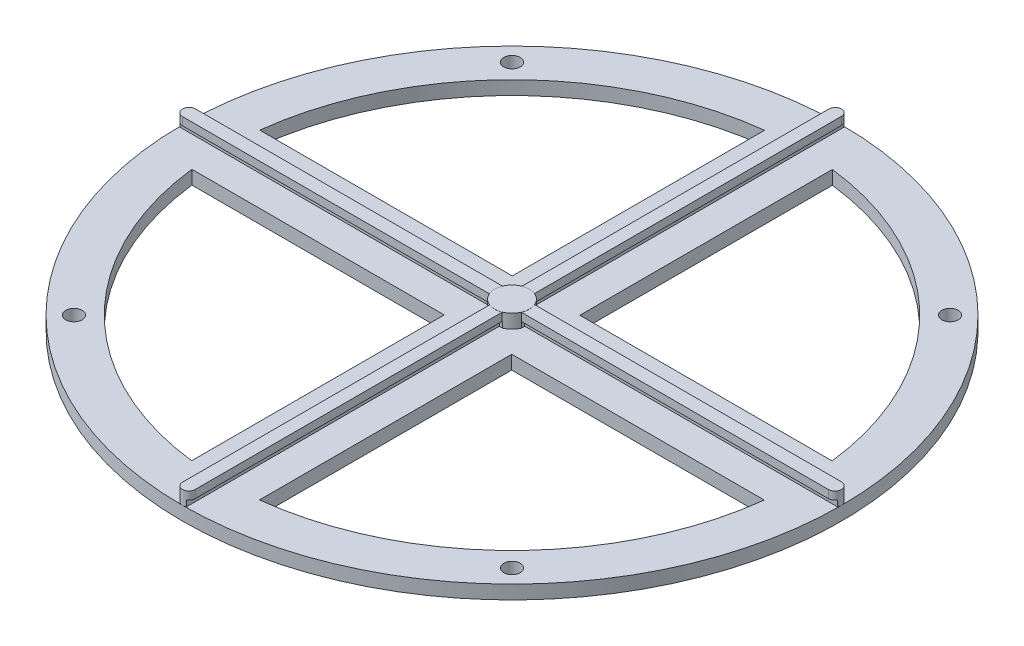
from build123d import *

# Parameters (mm, degrees)
SKETCH1_R                = 76.2
BOSS_EXTRUDE1_DEPTH      = 3.175
BOSS_EXTRUDE2_DEPTH      = 3.175
SKETCH3_R                = 4
BOSS_EXTRUDE3_DEPTH      = 0.0254
BOSS_EXTRUDE3_DEPTH_BACK = 6.35
CUT_EXTRUDE1_DEPTH       = 4.175
SKETCH6_W                = 72.50169985
SKETCH6_H                = 1.3335
CUT_EXTRUDE3_DEPTH       = 0.762
CIRPATTERN1_COUNT        = 4
SKETCH7_W                = 74.062567176
SKETCH7_H                = 1.3335
CUT_EXTRUDE4_DEPTH       = 0.762
CIRPATTERN2_COUNT        = 4
SKETCH8_R                = 1.905
CUT_EXTRUDE5_DEPTH       = 4.175


with BuildPart() as part:
    # Sketch1 → Boss-Extrude1 (new body)
    with BuildSketch(Plane(origin=(0, 0, 0), x_dir=(1, 0, 0), z_dir=(0, 1, 0))):
        Circle(SKETCH1_R)
    extrude(amount=BOSS_EXTRUDE1_DEPTH)

    # Sketch2 → Boss-Extrude2 (add)
    with BuildSketch(Plane(origin=(0, 3.175, 0), x_dir=(1, 0, 0), z_dir=(0, 1, 0))):
        with BuildLine():
            Line((-74.676, 1.524), (74.676, 1.524))
            ThreePointArc((74.676, 1.524), (76.2, 0), (74.676, -1.524))
            Line((74.676, -1.524), (-74.676, -1.524))
            ThreePointArc((-74.676, -1.524), (-76.2, 0), (-74.676, 1.524))
        make_face()
        with BuildLine():
            Line((1.4605, 74.7395), (1.4605, -74.7395))
            ThreePointArc((1.4605, -74.7395), (0, -76.2), (-1.4605, -74.7395))
            Line((-1.4605, -74.7395), (-1.4605, 74.7395))
            ThreePointArc((-1.4605, 74.7395), (0, 76.2), (1.4605, 74.7395))
        make_face()
    extrude(amount=BOSS_EXTRUDE2_DEPTH)

    # Sketch3 → Boss-Extrude3 (add, two sides)
    with BuildSketch(Plane(origin=(0, 6.35, 0), x_dir=(1, 0, 0), z_dir=(0, 1, 0))) as boss_extrude3_sk:
        Circle(SKETCH3_R)
    extrude(amount=BOSS_EXTRUDE3_DEPTH)
    extrude(boss_extrude3_sk.sketch, amount=-BOSS_EXTRUDE3_DEPTH_BACK)

    # Sketch4 → Cut-Extrude1 (cut, through all)
    with BuildSketch(Plane(origin=(0, 3.175, 0), x_dir=(1, 0, 0), z_dir=(0, 1, 0))):
        with BuildLine():
            Line((-7.8105, 7.874), (-39.5605, 7.874))
            Line((-39.5605, 7.874), (-63.009920838, 7.874))
            Line((-63.009920838, 7.874), (-66.208426571, 7.874))
            ThreePointArc((-66.208426571, 7.874), (-47.123731651, 47.168946779), (-7.8105, 66.215947586))
            Line((-7.8105, 66.215947586), (-7.8105, 63.017823588))
            Line((-7.8105, 63.017823588), (-7.8105, 7.874))
        make_face()
        with BuildLine():
            Line((7.874, 63.009920838), (7.874, 66.208426571))
            ThreePointArc((7.874, 66.208426571), (47.168946779, 47.123731651), (66.215947586, 7.8105))
            Line((66.215947586, 7.8105), (63.017823588, 7.8105))
            Line((63.017823588, 7.8105), (7.874, 7.8105))
            Line((7.874, 7.8105), (7.874, 39.5605))
            Line((7.874, 39.5605), (7.874, 63.009920838))
        make_face()
        with BuildLine():
            Line((63.009920838, -7.874), (66.208426571, -7.874))
            ThreePointArc((66.208426571, -7.874), (47.123731651, -47.168946779), (7.8105, -66.215947586))
            Line((7.8105, -66.215947586), (7.8105, -63.017823588))
            Line((7.8105, -63.017823588), (7.8105, -7.874))
            Line((7.8105, -7.874), (39.5605, -7.874))
            Line((39.5605, -7.874), (63.009920838, -7.874))
        make_face()
        with BuildLine():
            Line((-7.874, -63.009920838), (-7.874, -66.208426571))
            ThreePointArc((-7.874, -66.208426571), (-47.168946779, -47.123731651), (-66.215947586, -7.8105))
            Line((-66.215947586, -7.8105), (-63.017823588, -7.8105))
            Line((-63.017823588, -7.8105), (-7.874, -7.8105))
            Line((-7.874, -7.8105), (-7.874, -39.5605))
            Line((-7.874, -39.5605), (-7.874, -63.009920838))
        make_face()
    extrude(amount=-CUT_EXTRUDE1_DEPTH, mode=Mode.SUBTRACT)

    # Sketch6 → Cut-Extrude3 (cut)
    with BuildSketch(Plane.XY.offset(1.524)):
        with Locations((39.949150075, 3.84175)):
            Rectangle(SKETCH6_W, SKETCH6_H)
    cut_extrude3 = extrude(amount=-CUT_EXTRUDE3_DEPTH, mode=Mode.SUBTRACT)

    # CirPattern1: Cut-Extrude3 ×4 about axis
    cirpattern1_axis = Axis((0, 0, 0), (0, 1, 0))
    for i in range(1, CIRPATTERN1_COUNT):
        add(cut_extrude3.rotate(cirpattern1_axis, i * 360 / CIRPATTERN1_COUNT), mode=Mode.SUBTRACT)

    # Sketch7 → Cut-Extrude4 (cut)
    with BuildSketch(Plane(origin=(0, 0, -1.524), x_dir=(-1, 0, 0), z_dir=(0, 0, -1))):
        with Locations((-40.729583738, 3.84175)):
            Rectangle(SKETCH7_W, SKETCH7_H)
    cut_extrude4 = extrude(amount=-CUT_EXTRUDE4_DEPTH, mode=Mode.SUBTRACT)

    # CirPattern2: Cut-Extrude4 ×4 about axis
    cirpattern2_axis = Axis((0, 0, 0), (0, 1, 0))
    for i in range(1, CIRPATTERN2_COUNT):
        add(cut_extrude4.rotate(cirpattern2_axis, i * 360 / CIRPATTERN2_COUNT), mode=Mode.SUBTRACT)

    # Sketch8 → Cut-Extrude5 (cut, through all)
    with BuildSketch(Plane(origin=(0, 3.175, 0), x_dir=(1, 0, 0), z_dir=(0, 1, 0))):
        with Locations((-50.648644523, -50.648644523)):
            Circle(SKETCH8_R)
        with Locations((-50.648644523, 50.648644523)):
            Circle(SKETCH8_R)
        with Locations((50.648644523, 50.648644523)):
            Circle(SKETCH8_R)
        with Locations((50.648644523, -50.648644523)):
            Circle(SKETCH8_R)
    extrude(amount=-CUT_EXTRUDE5_DEPTH, mode=Mode.SUBTRACT)


solid = part.part
